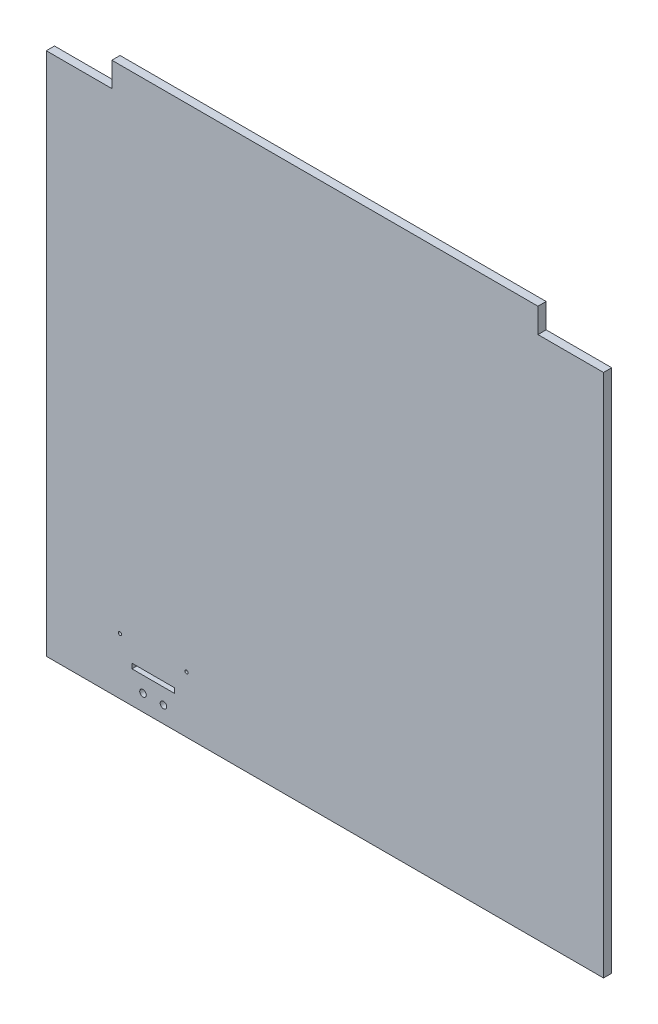
from build123d import *

# Parameters (mm, degrees)
ESQUISSE1_W             = 680
ESQUISSE1_H             = 670
BOSS_EXTRU_1_DEPTH      = 10
ESQUISSE2_W             = 80
ESQUISSE2_H             = 30
ENL_V_MAT_EXTRU_1_DEPTH = 11
ESQUISSE3_W             = 52
ESQUISSE3_H             = 6
ENL_V_MAT_EXTRU_2_DEPTH = 11
ESQUISSE4_R             = 4
ENL_V_MAT_EXTRU_3_DEPTH = 11
ESQUISSE5_R             = 2
ENL_V_MAT_EXTRU_4_DEPTH = 11


with BuildPart() as part:
    # Esquisse1 → Boss.-Extru.1 (new body)
    with BuildSketch(Plane.XY):
        Rectangle(ESQUISSE1_W, ESQUISSE1_H)
    extrude(amount=BOSS_EXTRU_1_DEPTH)

    # Esquisse2 → Enlèv. mat.-Extru.1 (cut, through all)
    with BuildSketch(Plane.XY.offset(10)):
        with Locations((-300, 320)):
            Rectangle(ESQUISSE2_W, ESQUISSE2_H)
        with Locations((300, 320)):
            Rectangle(ESQUISSE2_W, ESQUISSE2_H)
    extrude(amount=-ENL_V_MAT_EXTRU_1_DEPTH, mode=Mode.SUBTRACT)

    # Esquisse3 → Enlèv. mat.-Extru.2 (cut, through all)
    with BuildSketch(Plane.XY.offset(10)):
        with Locations((-209.5, -293)):
            Rectangle(ESQUISSE3_W, ESQUISSE3_H)
    extrude(amount=-ENL_V_MAT_EXTRU_2_DEPTH, mode=Mode.SUBTRACT)

    # Esquisse4 → Enlèv. mat.-Extru.3 (cut, through all)
    with BuildSketch(Plane.XY.offset(10)):
        with Locations((-222, -315)):
            Circle(ESQUISSE4_R)
        with Locations((-197, -315)):
            Circle(ESQUISSE4_R)
    extrude(amount=-ENL_V_MAT_EXTRU_3_DEPTH, mode=Mode.SUBTRACT)

    # Esquisse5 → Enlèv. mat.-Extru.4 (cut, through all)
    with BuildSketch(Plane.XY.offset(10)):
        with Locations((-250, -266)):
            Circle(ESQUISSE5_R)
        with Locations((-169, -266)):
            Circle(ESQUISSE5_R)
    extrude(amount=-ENL_V_MAT_EXTRU_4_DEPTH, mode=Mode.SUBTRACT)


solid = part.part
